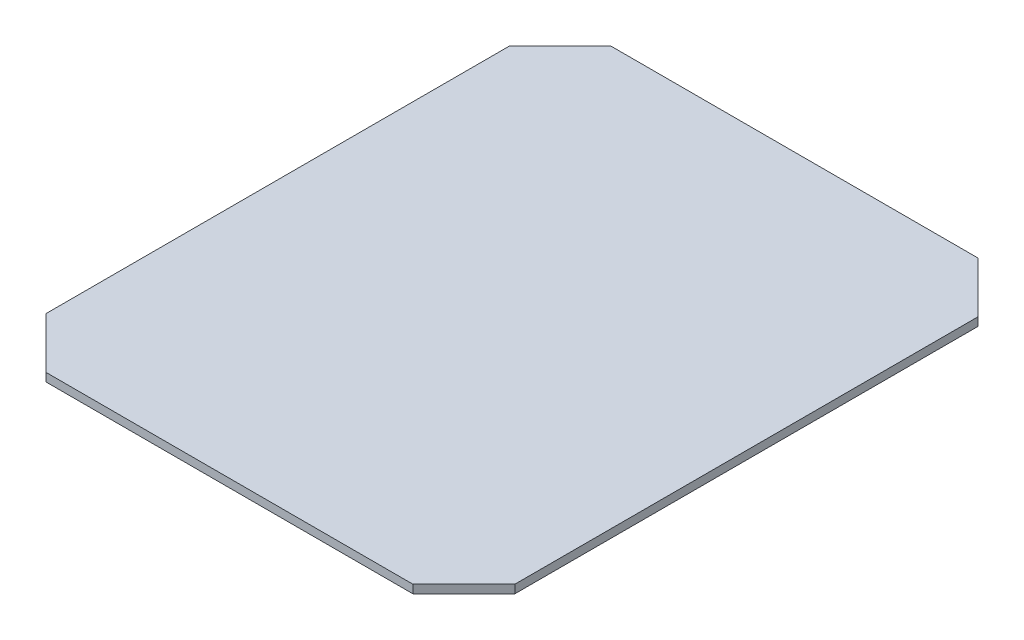
from build123d import *

# Parameters (mm, degrees)
SKETCH1_W           = 506.5
SKETCH1_H           = 610.5
BOSS_EXTRUDE1_DEPTH = 9
CUT_EXTRUDE1_DEPTH  = 10


with BuildPart() as part:
    # Sketch1 → Boss-Extrude1 (new body)
    with BuildSketch(Plane(origin=(0, 0, 0), x_dir=(1, 0, 0), z_dir=(0, 1, 0))):
        with Locations((253.25, 305.25)):
            Rectangle(SKETCH1_W, SKETCH1_H)
    extrude(amount=BOSS_EXTRUDE1_DEPTH)

    # Sketch2 → Cut-Extrude1 (cut, through all)
    with BuildSketch(Plane(origin=(0, 9, 0), x_dir=(1, 0, 0), z_dir=(0, 1, 0))):
        Polygon((0, 0), (55, 0), (0, 55), align=None)
        Polygon((506.5, 0), (451.5, 0), (506.5, 55), align=None)
        Polygon((506.5, 610.5), (506.5, 555.5), (451.5, 610.5), align=None)
        Polygon((0, 610.5), (55, 610.5), (0, 555.5), align=None)
    extrude(amount=-CUT_EXTRUDE1_DEPTH, mode=Mode.SUBTRACT)


solid = part.part
